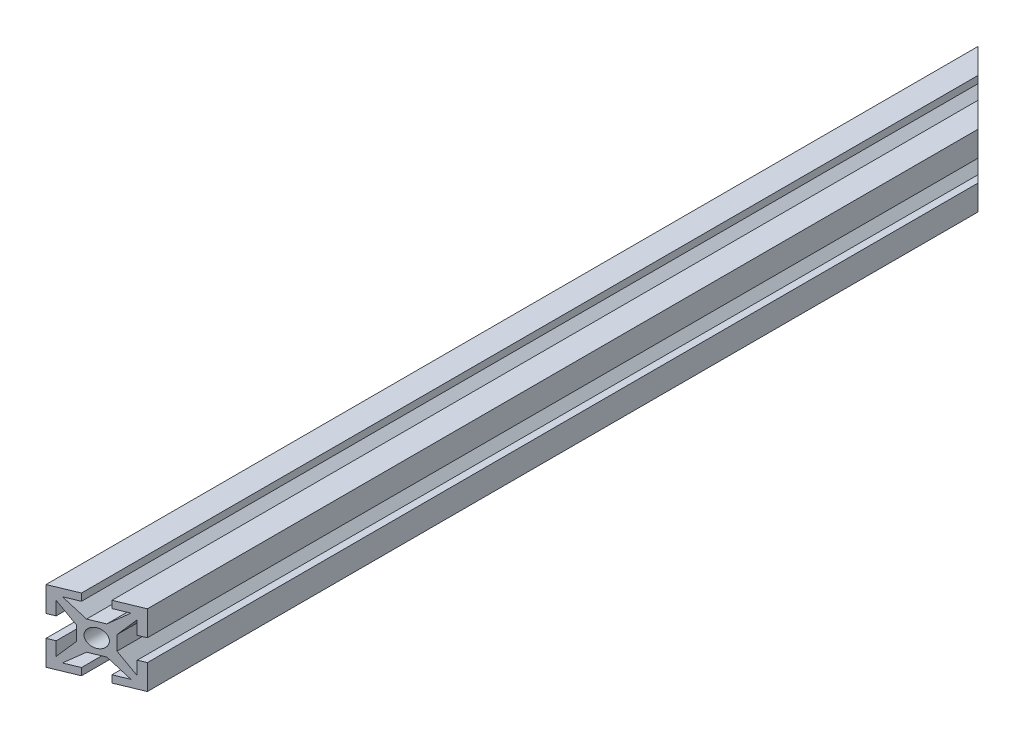
from build123d import *

# Parameters (mm, degrees)
ESQUISSE2_R             = 1.25
BOSS_EXTRU_1_DEPTH      = 130
ENL_V_MAT_EXTRU_1_DEPTH = 11


with BuildPart() as part:
    # Esquisse2 → Boss.-Extru.1 (new body)
    with BuildSketch(Plane.XY):
        Polygon((-1, -2), (1, -2), (3.383507185, -4), (1.5, -4), (1.5, -5), (5, -5), (5, -1.5), (4, -1.5), (4, -3.383507185), (2, -1), (2, 1), (4, 3.383507185), (4, 1.5), (5, 1.5), (5, 5), (1.5, 5), (1.5, 4), (3.383507185, 4), (1, 2), (-1, 2), (-3.383507185, 4), (-1.5, 4), (-1.5, 5), (-5, 5), (-5, 1.5), (-4, 1.5), (-4, 3.383507185), (-2, 1), (-2, -1), (-4, -3.383507185), (-4, -1.5), (-5, -1.5), (-5, -5), (-1.5, -5), (-1.5, -4), (-3.383507185, -4), align=None)
        Circle(ESQUISSE2_R, mode=Mode.SUBTRACT)
    extrude(amount=BOSS_EXTRU_1_DEPTH)

    # Esquisse3 → Enlèv. mat.-Extru.1 (cut, through all)
    with BuildSketch(Plane(origin=(0, 5, 0), x_dir=(1, 0, 0), z_dir=(0, 1, 0))):
        Polygon((-5, 0), (5, 0), (5, -10), align=None)
        Polygon((5, -125.857864376), (-5, -130), (5, -130), align=None)
    extrude(amount=-ENL_V_MAT_EXTRU_1_DEPTH, mode=Mode.SUBTRACT)


solid = part.part
